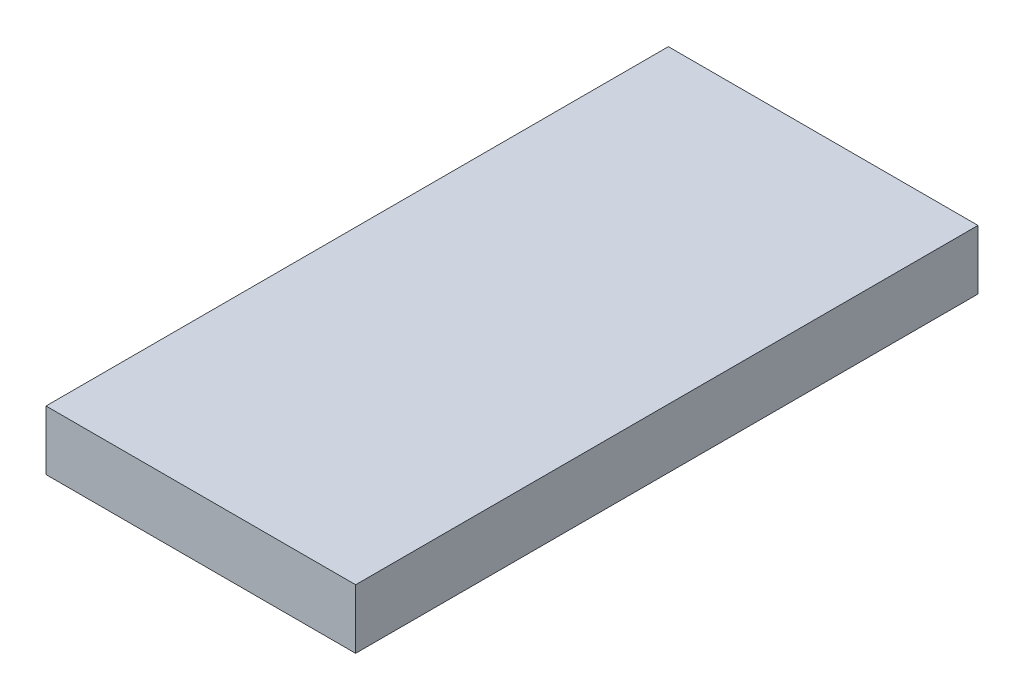
from build123d import *

# Parameters (mm, degrees)
SKETCH1_W           = 12.573
SKETCH1_H           = 25.273
BOSS_EXTRUDE1_DEPTH = 2.413


with BuildPart() as part:
    # Sketch1 → Boss-Extrude1 (new body)
    with BuildSketch(Plane(origin=(0, 0, 0), x_dir=(1, 0, 0), z_dir=(0, 1, 0))):
        Rectangle(SKETCH1_W, SKETCH1_H)
    extrude(amount=BOSS_EXTRUDE1_DEPTH)


solid = part.part
